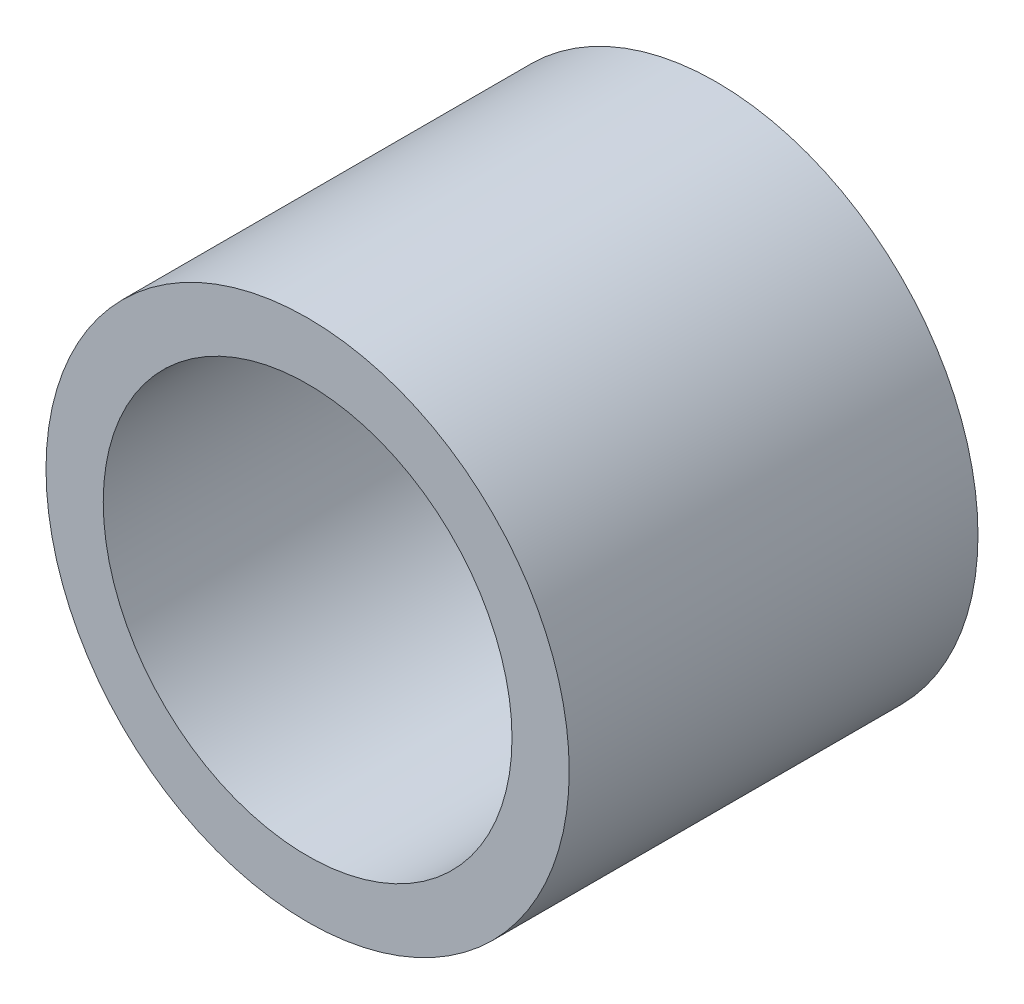
from build123d import *

# Parameters (mm, degrees)
SKETCH1_R           = 16
SKETCH1_R_2         = 12.5
BOSS_EXTRUDE1_DEPTH = 12.5


with BuildPart() as part:
    # Sketch1 → Boss-Extrude1 (new body, symmetric)
    with BuildSketch(Plane.XY):
        Circle(SKETCH1_R)
        Circle(SKETCH1_R_2, mode=Mode.SUBTRACT)
    extrude(amount=BOSS_EXTRUDE1_DEPTH, both=True)


solid = part.part
